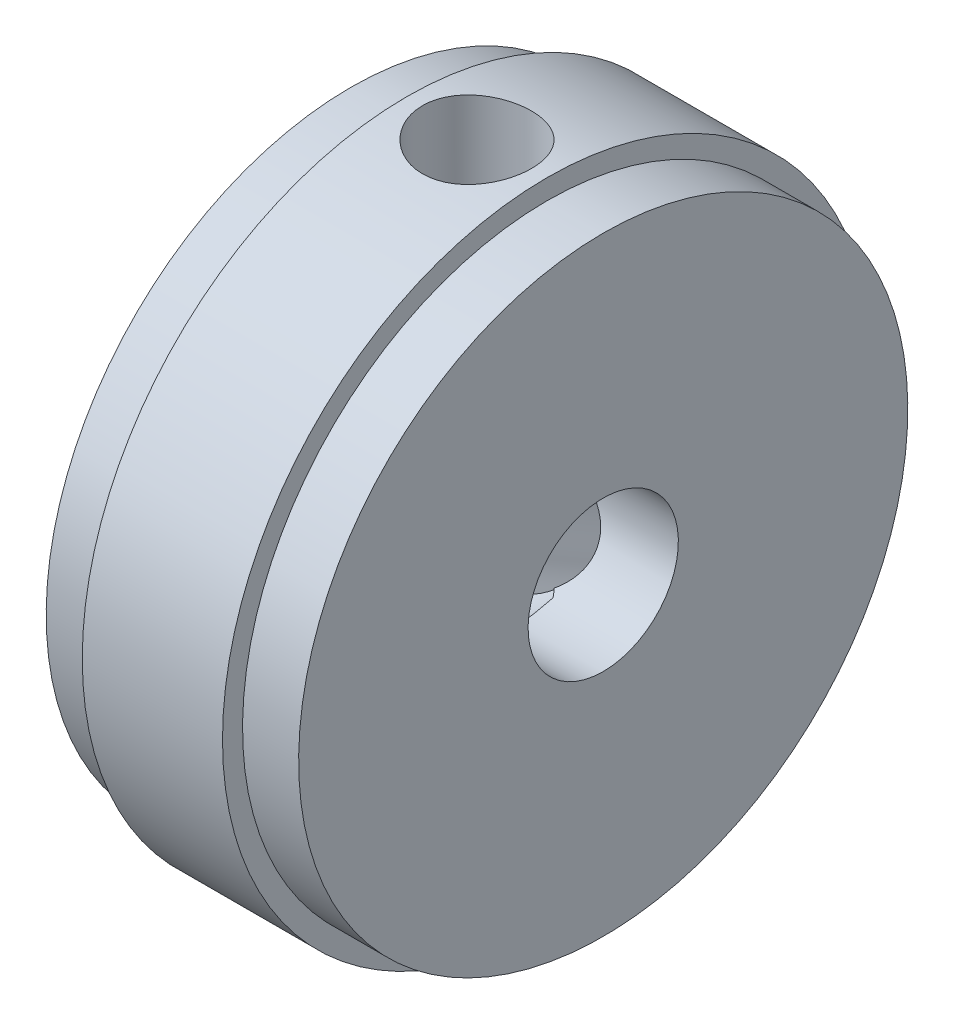
from build123d import *

# Parameters (mm, degrees)
SKETCH2_R          = 2.38125
CUT_EXTRUDE1_DEPTH = 9
CIRPATTERN1_COUNT  = 2
CIRPATTERN1_ANGLE  = 120


with BuildPart() as part:
    # Sketch1 → Revolve1 (revolve)
    with BuildSketch(Plane.XY):
        Polygon((4, 0), (-4, 0), (-4, 9.652), (-2.222, 9.652), (-2.222, 10.287), (2.222, 10.287), (2.222, 9.652), (4, 9.652), align=None)
    revolve(axis=Axis((8.430806561, 0, 0), (-1, 0, 0)))

    # Sketch2 → Cut-Extrude1 (cut, through all)
    with BuildSketch(Plane.ZY.offset(4)):
        Circle(SKETCH2_R)
    extrude(amount=-CUT_EXTRUDE1_DEPTH, mode=Mode.SUBTRACT)

    # Sketch4 → #8-32 Tapped Hole1 (revolve, cut)
    with BuildSketch(Plane(origin=(0, 10.287, 0), x_dir=(0, 0, 1), z_dir=(1, 0, 0))):
        Polygon((0, 0), (0, 13.483806461), (1.7272, 12.446), (1.7272, 0), align=None)
    f_8_32_tapped_hole1 = revolve(axis=Axis((0, 16.637, 0), (0, -1, 0)), mode=Mode.SUBTRACT)

    # CirPattern1: #8-32 Tapped Hole1 ×2 about axis
    cirpattern1_axis = Axis((4, 0, 0), (-1, 0, 0))
    for i in range(1, CIRPATTERN1_COUNT):
        add(f_8_32_tapped_hole1.rotate(cirpattern1_axis, i * CIRPATTERN1_ANGLE / (CIRPATTERN1_COUNT - 1)), mode=Mode.SUBTRACT)


solid = part.part
